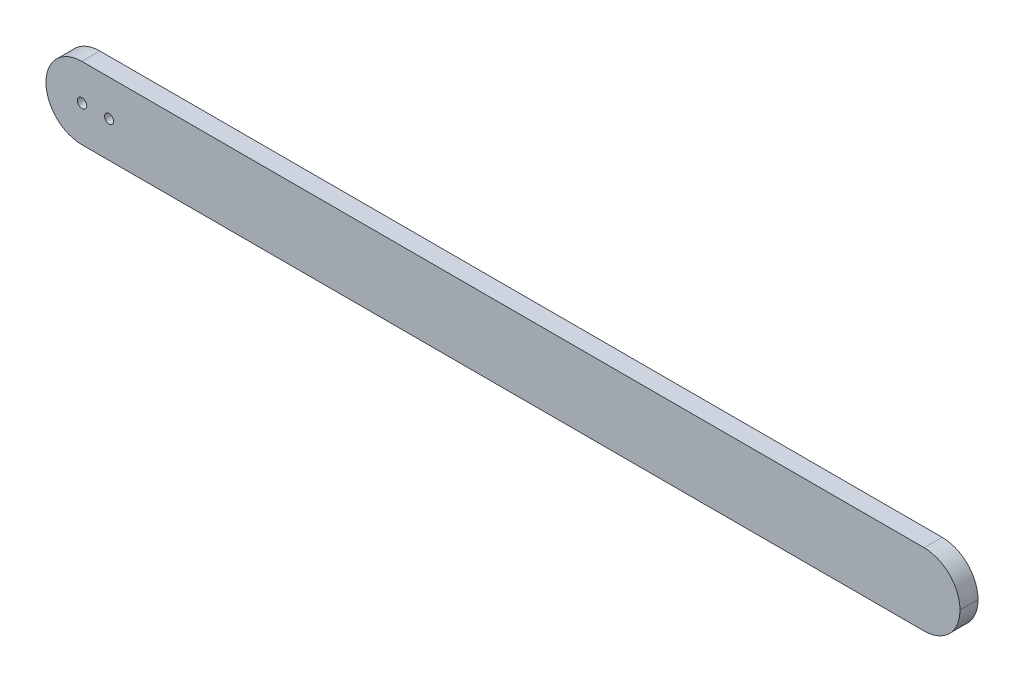
from build123d import *

# Parameters (mm, degrees)
BOSS_EXTRUDE1_DEPTH = 19.05
SKETCH3_R           = 16.66875
CUT_EXTRUDE1_DEPTH  = 9.525
SKETCH5_R           = 4.9609375
SKETCH5_R_2         = 4.7625
CUT_EXTRUDE10_DEPTH = 19.05


with BuildPart() as part:
    # Sketch2 → Boss-Extrude1 (new body)
    with BuildSketch(Plane.XY):
        with BuildLine():
            Line((37.846, 0), (927.354, 0))
            ThreePointArc((927.354, 0), (954.115163241, -11.084836759), (965.2, -37.846))
            Line((965.2, -37.846), (965.2, -38.354))
            ThreePointArc((965.2, -38.354), (954.115163241, -65.115163241), (927.354, -76.2))
            Line((927.354, -76.2), (37.846, -76.2))
            ThreePointArc((37.846, -76.2), (11.084836759, -65.115163241), (0, -38.354))
            Line((0, -38.354), (0, -37.846))
            ThreePointArc((0, -37.846), (11.084836759, -11.084836759), (37.846, 0))
        make_face()
    extrude(amount=BOSS_EXTRUDE1_DEPTH)

    # Sketch3 → Cut-Extrude1 (cut)
    with BuildSketch(Plane.XY):
        with Locations((120.65, -38.1)):
            Circle(SKETCH3_R)
        with Locations((241.3, -38.1)):
            Circle(SKETCH3_R)
        with Locations((361.95, -38.1)):
            Circle(SKETCH3_R)
        with Locations((844.55, -38.1)):
            Circle(SKETCH3_R)
        with Locations((723.9, -38.1)):
            Circle(SKETCH3_R)
        with Locations((603.25, -38.1)):
            Circle(SKETCH3_R)
        with Locations((482.6, -38.1)):
            Circle(SKETCH3_R)
    extrude(amount=CUT_EXTRUDE1_DEPTH, mode=Mode.SUBTRACT)

    # Sketch5 → Cut-Extrude10 (cut)
    with BuildSketch(Plane.XY):
        with Locations((38.1, -38.1)):
            Circle(SKETCH5_R)
        with Locations((66.675, -38.1)):
            Circle(SKETCH5_R_2)
    extrude(amount=CUT_EXTRUDE10_DEPTH, mode=Mode.SUBTRACT)


solid = part.part
